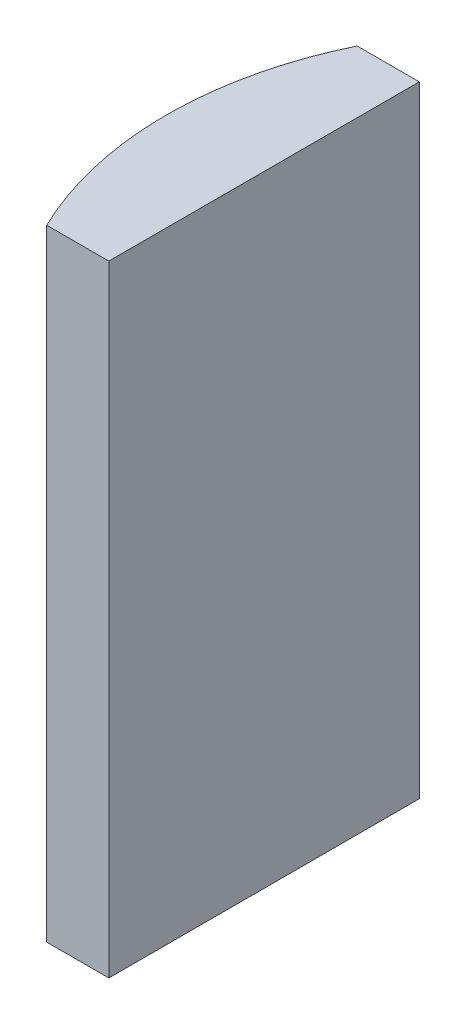
from build123d import *

# Parameters (mm, degrees)
EXTRUDE_1_DEPTH = 20


with BuildPart() as part:
    # 草图1 → 凸台-拉伸1 (new body)
    with BuildSketch(Plane(origin=(0, 0, 0), x_dir=(1, 0, 0), z_dir=(0, 1, 0))):
        with BuildLine():
            Line((-5.945402443, 5), (-3.944795665, 5))
            Line((-3.944795665, 5), (-3.944795665, -5))
            Line((-3.944795665, -5), (-5.945402443, -5))
            ThreePointArc((-5.945402443, -5), (-7.094795665, 0), (-5.945402443, 5))
        make_face()
    extrude(amount=EXTRUDE_1_DEPTH)


solid = part.part
